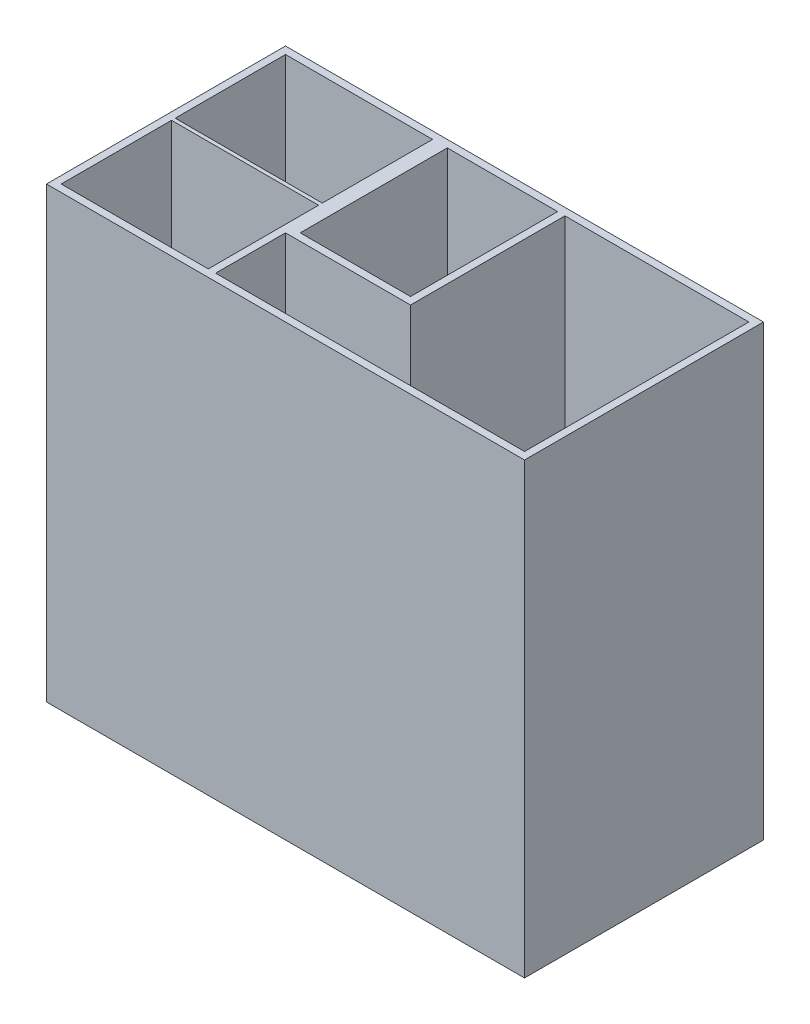
from build123d import *

# Parameters (mm, degrees)
SKETCH1_W           = 130
SKETCH1_H           = 65
BOSS_EXTRUDE1_DEPTH = 2
SKETCH2_W           = 130
SKETCH2_H           = 65
SKETCH2_W_2         = 126
SKETCH2_H_2         = 61
BOSS_EXTRUDE2_DEPTH = 120
SKETCH4_W           = 40
SKETCH4_H           = 1
SKETCH4_W_2         = 2
SKETCH4_H_2         = 19
SKETCH4_H_3         = 40
BOSS_EXTRUDE3_DEPTH = 120


with BuildPart() as part:
    # Sketch1 → Boss-Extrude1 (new body)
    with BuildSketch(Plane(origin=(0, 0, 0), x_dir=(1, 0, 0), z_dir=(0, 1, 0))):
        Rectangle(SKETCH1_W, SKETCH1_H)
    extrude(amount=BOSS_EXTRUDE1_DEPTH)

    # Sketch2 → Boss-Extrude2 (add)
    with BuildSketch(Plane(origin=(0, 2, 0), x_dir=(1, 0, 0), z_dir=(0, 1, 0))):
        Rectangle(SKETCH2_W, SKETCH2_H)
        Rectangle(SKETCH2_W_2, SKETCH2_H_2, mode=Mode.SUBTRACT)
    extrude(amount=BOSS_EXTRUDE2_DEPTH)

    # Sketch4 → Boss-Extrude3 (add)
    with BuildSketch(Plane(origin=(0, 2, 0), x_dir=(1, 0, 0), z_dir=(0, 1, 0))):
        Polygon((-21, 30.5), (-23, 30.5), (-23, 0.5), (-23, -0.5), (-23, -9.5), (-19, -9.5), (-19, 30.5), align=None)
        with Locations((-43, 0)):
            Rectangle(SKETCH4_W, SKETCH4_H)
        with Locations((-22, -21)):
            Rectangle(SKETCH4_W_2, SKETCH4_H_2)
        Polygon((11, -9.5), (-19, -9.5), (-23, -9.5), (-23, -11.5), (-21, -11.5), (13, -11.5), (13, -9.5), align=None)
        with Locations((12, 10.5)):
            Rectangle(SKETCH4_W_2, SKETCH4_H_3)
    extrude(amount=BOSS_EXTRUDE3_DEPTH)


solid = part.part
